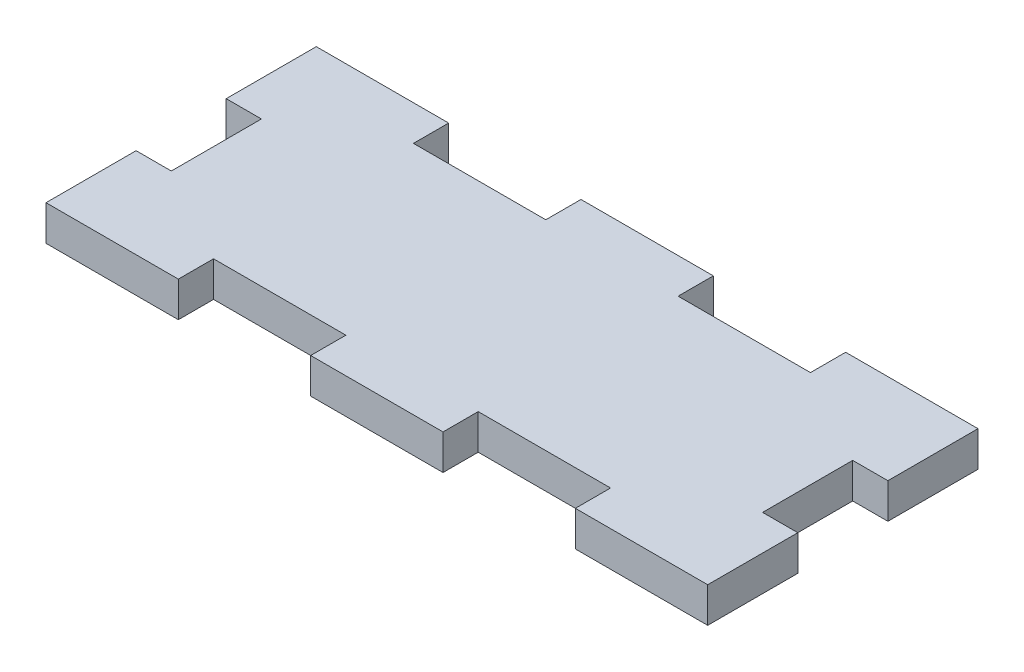
from build123d import *

# Parameters (mm, degrees)
SKETCH1_W           = 59.69
SKETCH1_H           = 24.384
BOSS_EXTRUDE2_DEPTH = 3.175
SKETCH3_W           = 11.938
SKETCH3_H           = 3.175
CUT_EXTRUDE2_DEPTH  = 3.175
LPATTERN2_COUNT     = 2
LPATTERN2_PITCH     = 23.876
SKETCH4_W           = 6.35
SKETCH4_H           = 8.128
CUT_EXTRUDE3_DEPTH  = 3.175


with BuildPart() as part:
    # Sketch1 → Boss-Extrude2 (new body)
    with BuildSketch(Plane(origin=(0, 0, 0), x_dir=(1, 0, 0), z_dir=(0, 1, 0))):
        Rectangle(SKETCH1_W, SKETCH1_H)
    extrude(amount=BOSS_EXTRUDE2_DEPTH)

    # Sketch3 → Cut-Extrude2 (cut)
    with BuildSketch(Plane(origin=(0, 3.175, 0), x_dir=(1, 0, 0), z_dir=(0, 1, 0))):
        with Locations((11.938, 10.6045)):
            Rectangle(SKETCH3_W, SKETCH3_H)
        with Locations((11.938, -10.6045)):
            Rectangle(SKETCH3_W, SKETCH3_H)
    cut_extrude2 = extrude(amount=-CUT_EXTRUDE2_DEPTH, mode=Mode.SUBTRACT)

    # LPattern2: Cut-Extrude2 ×2
    with Locations(*[(-i * LPATTERN2_PITCH, 0, 0) for i in range(1, LPATTERN2_COUNT)]):
        add(cut_extrude2, mode=Mode.SUBTRACT)

    # Sketch4 → Cut-Extrude3 (cut)
    with BuildSketch(Plane(origin=(0, 3.175, 0), x_dir=(1, 0, 0), z_dir=(0, 1, 0))):
        with Locations((-29.845, 0)):
            Rectangle(SKETCH4_W, SKETCH4_H)
        with Locations((29.845, 0)):
            Rectangle(SKETCH4_W, SKETCH4_H)
    extrude(amount=-CUT_EXTRUDE3_DEPTH, mode=Mode.SUBTRACT)


solid = part.part
